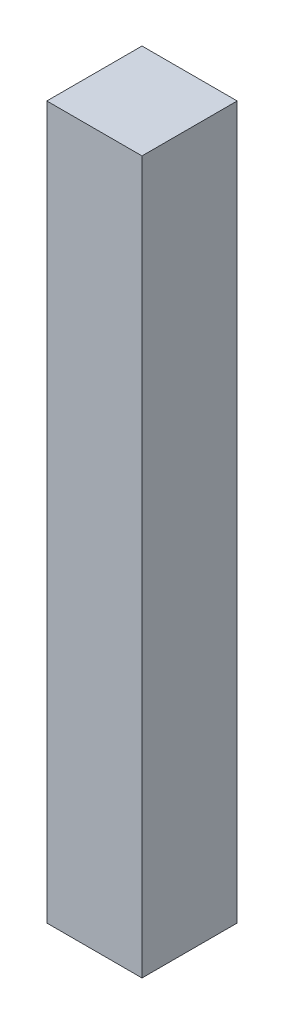
from build123d import *

# Parameters (mm, degrees)
SKETCH1_W           = 25.4
SKETCH1_H           = 25.4
BOSS_EXTRUDE1_DEPTH = 190


with BuildPart() as part:
    # Sketch1 → Boss-Extrude1 (new body)
    with BuildSketch(Plane(origin=(0, 0, 0), x_dir=(1, 0, 0), z_dir=(0, 1, 0))):
        Rectangle(SKETCH1_W, SKETCH1_H)
    extrude(amount=BOSS_EXTRUDE1_DEPTH)


solid = part.part
